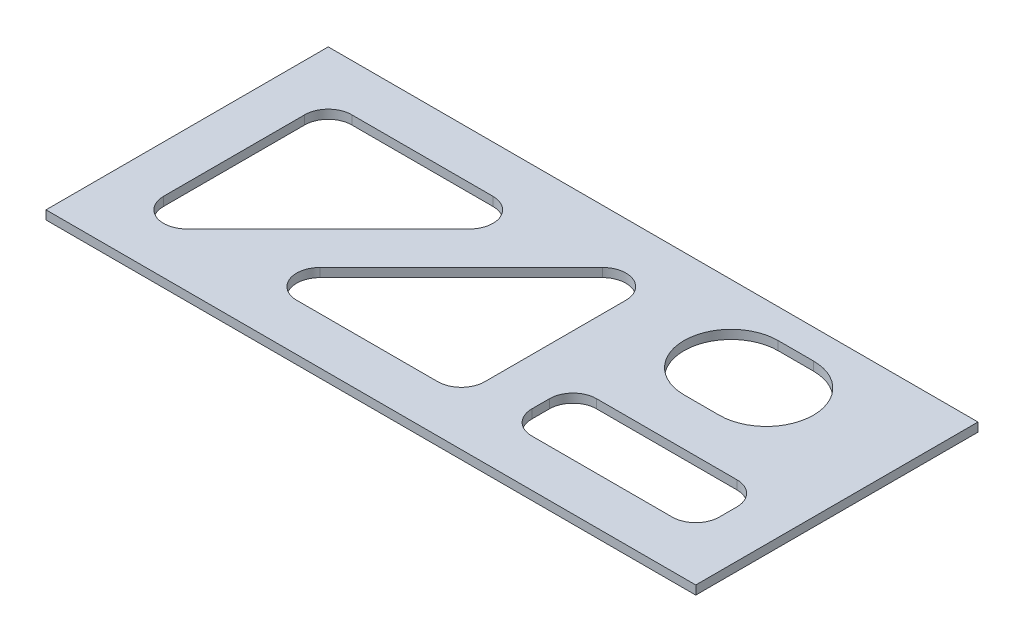
from build123d import *

# Parameters (mm, degrees)
SKETCH1_W           = 350.8375
SKETCH1_H           = 152.4
BOSS_EXTRUDE1_DEPTH = 2.38125
CUT_EXTRUDE1_DEPTH  = 5.7625


with BuildPart() as part:
    # Sketch1 → Boss-Extrude1 (new body, symmetric)
    with BuildSketch(Plane(origin=(0, 0, 0), x_dir=(1, 0, 0), z_dir=(0, 1, 0))):
        Rectangle(SKETCH1_W, SKETCH1_H)
    extrude(amount=BOSS_EXTRUDE1_DEPTH, both=True)

    # Sketch2 → Cut-Extrude1 (cut, through all)
    with BuildSketch(Plane(origin=(0, 2.38125, 0), x_dir=(1, 0, 0), z_dir=(0, 1, 0))):
        with BuildLine():
            Line((102.39375, 9.525), (83.34375, 9.525))
            ThreePointArc((83.34375, 9.525), (57.94375, 34.925), (83.34375, 60.325))
            Line((83.34375, 60.325), (102.39375, 60.325))
            ThreePointArc((102.39375, 60.325), (127.79375, 34.925), (102.39375, 9.525))
        make_face()
        with BuildLine():
            Line((-137.31875, 50.8), (-61.11875, 50.8))
            ThreePointArc((-61.11875, 50.8), (-49.385479937, 42.960079591), (-52.138493879, 29.119743879))
            Line((-52.138493879, 29.119743879), (-128.338493879, -47.080256121))
            ThreePointArc((-128.338493879, -47.080256121), (-142.178829591, -49.833270063), (-150.01875, -38.1))
            Line((-150.01875, -38.1), (-150.01875, 38.1))
            ThreePointArc((-150.01875, 38.1), (-146.299006121, 47.080256121), (-137.31875, 50.8))
        make_face()
        with BuildLine():
            Line((-65.476701031, -50.8), (10.723298969, -50.8))
            ThreePointArc((10.723298969, -50.8), (19.70355509, -47.080256121), (23.423298969, -38.1))
            Line((23.423298969, -38.1), (23.423298969, 38.1))
            ThreePointArc((23.423298969, 38.1), (15.58337856, 49.833270063), (1.743042847, 47.080256121))
            Line((1.743042847, 47.080256121), (-74.456957153, -29.119743879))
            ThreePointArc((-74.456957153, -29.119743879), (-77.209971094, -42.960079591), (-65.476701031, -50.8))
        make_face()
        with BuildLine():
            Line((61.523298969, -50.8), (137.31875, -50.8))
            ThreePointArc((137.31875, -50.8), (146.299006121, -47.080256121), (150.01875, -38.1))
            Line((150.01875, -38.1), (150.01875, -28.575))
            ThreePointArc((150.01875, -28.575), (146.299006121, -19.594743879), (137.31875, -15.875))
            Line((137.31875, -15.875), (61.523298969, -15.875))
            ThreePointArc((61.523298969, -15.875), (52.543042847, -19.594743879), (48.823298969, -28.575))
            Line((48.823298969, -28.575), (48.823298969, -38.1))
            ThreePointArc((48.823298969, -38.1), (52.543042847, -47.080256121), (61.523298969, -50.8))
        make_face()
    extrude(amount=-CUT_EXTRUDE1_DEPTH, mode=Mode.SUBTRACT)


solid = part.part
